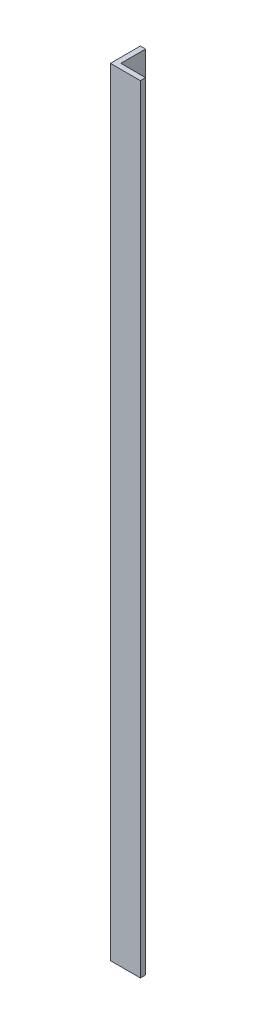
from build123d import *

# Parameters (mm, degrees)
BOSS_EXTRUDE1_DEPTH = 500


with BuildPart() as part:
    # Sketch1 → Boss-Extrude1 (new body)
    with BuildSketch(Plane(origin=(0, 0, 0), x_dir=(1, 0, 0), z_dir=(0, 1, 0))):
        Polygon((0, 0), (0, 19.31), (3.35, 19.31), (3.35, 3.35), (19.31, 3.35), (19.31, 0), align=None)
    extrude(amount=BOSS_EXTRUDE1_DEPTH)


solid = part.part
